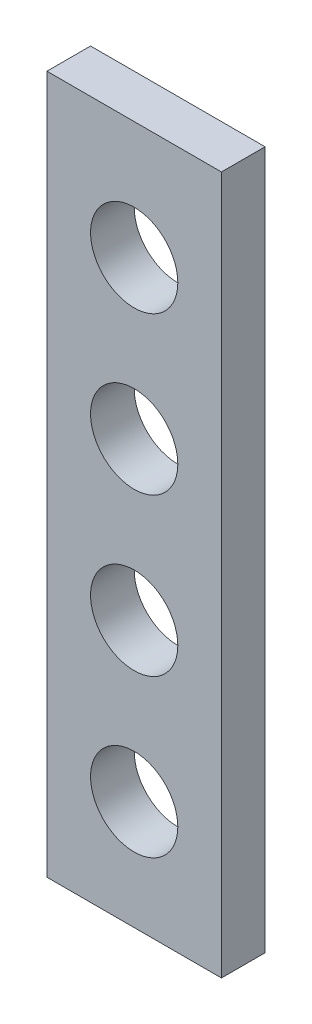
from build123d import *

# Parameters (mm, degrees)
SKETCH1_W           = 40
SKETCH1_H           = 160
BOSS_EXTRUDE1_DEPTH = 10
SKETCH2_R           = 10
CUT_EXTRUDE1_DEPTH  = 11
LPATTERN1_COUNT     = 4
LPATTERN1_PITCH     = 36


with BuildPart() as part:
    # Sketch1 → Boss-Extrude1 (new body)
    with BuildSketch(Plane.XY):
        with Locations((-128.294392523, 130.11682243)):
            Rectangle(SKETCH1_W, SKETCH1_H)
    extrude(amount=BOSS_EXTRUDE1_DEPTH)

    # Sketch2 → Cut-Extrude1 (cut, through all)
    with BuildSketch(Plane.XY.offset(10)):
        with Locations((-128.294392523, 75.11682243)):
            Circle(SKETCH2_R)
    cut_extrude1 = extrude(amount=-CUT_EXTRUDE1_DEPTH, mode=Mode.SUBTRACT)

    # LPattern1: Cut-Extrude1 ×4
    with Locations(*[(0, i * LPATTERN1_PITCH, 0) for i in range(1, LPATTERN1_COUNT)]):
        add(cut_extrude1, mode=Mode.SUBTRACT)


solid = part.part
